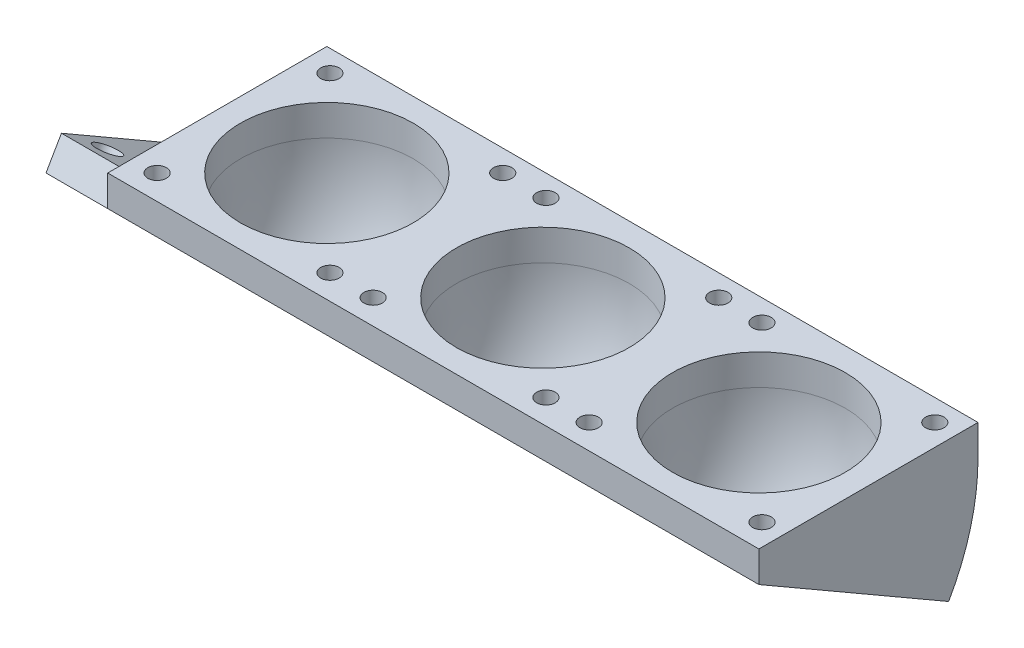
from build123d import *

# Parameters (mm, degrees)
SKETCH1_W           = 71
SKETCH1_H           = 71
SKETCH1_R           = 3
SKETCH1_R_2         = 28
BOSS_EXTRUDE1_DEPTH = 10
SKETCH2_W           = 71
SKETCH2_H           = 71
SKETCH2_R           = 28
REVOLVE1_ANGLE      = 30
LPATTERN1_COUNT     = 3
LPATTERN1_PITCH     = 70
SKETCH3_W           = 20
SKETCH3_H           = 71
BOSS_EXTRUDE2_DEPTH = 10
SKETCH4_R           = 4
CUT_EXTRUDE1_DEPTH  = 10


with BuildPart() as part:
    # Sketch1 → Boss-Extrude1 (new body)
    with BuildSketch(Plane(origin=(0, 0, 0), x_dir=(1, 0, 0), z_dir=(0, 1, 0))):
        with Locations((-15.992227979, 8.554404145)):
            Rectangle(SKETCH1_W, SKETCH1_H)
        with Locations((-43.492227979, 37.054404145)):
            Circle(SKETCH1_R, mode=Mode.SUBTRACT)
        with Locations((12.507772021, 37.054404145)):
            Circle(SKETCH1_R, mode=Mode.SUBTRACT)
        with Locations((12.507772021, -18.945595855)):
            Circle(SKETCH1_R, mode=Mode.SUBTRACT)
        with Locations((-43.492227979, -18.945595855)):
            Circle(SKETCH1_R, mode=Mode.SUBTRACT)
        with Locations((-15.992227979, 8.554404145)):
            Circle(SKETCH1_R_2, mode=Mode.SUBTRACT)
    boss_extrude1 = extrude(amount=BOSS_EXTRUDE1_DEPTH)

    # Sketch2 → Revolve1 (revolve)
    with BuildSketch(Plane.XZ):
        with Locations((-15.992227979, -8.554404145)):
            Rectangle(SKETCH2_W, SKETCH2_H)
        with Locations((-15.992227979, -8.554404145)):
            Circle(SKETCH2_R, mode=Mode.SUBTRACT)
    revolve1 = revolve(axis=Axis((19.507772021, 0, 26.945595855), (-1, 0, 0)), revolution_arc=REVOLVE1_ANGLE)

    # LPattern1: Boss-Extrude1, Revolve1 ×3
    with Locations(*[(i * LPATTERN1_PITCH, 0, 0) for i in range(1, LPATTERN1_COUNT)]):
        add(boss_extrude1)
        add(revolve1)

    # Sketch3 → Boss-Extrude2 (add)
    with BuildSketch(Plane(origin=(0, -11.667785265, 6.736398964), x_dir=(1, 0, 0), z_dir=(0, -0.866025404, 0.5))):
        with Locations((-61.492227979, -12.16442947)):
            Rectangle(SKETCH3_W, SKETCH3_H)
    extrude(amount=-BOSS_EXTRUDE2_DEPTH)

    # Sketch4 → Cut-Extrude1 (cut)
    with BuildSketch(Plane(origin=(0, -11.667785265, 6.736398964), x_dir=(1, 0, 0), z_dir=(0, -0.866025404, 0.5))):
        with Locations((-63.492227979, 15.33557053)):
            Circle(SKETCH4_R)
        with Locations((-63.492227979, -39.66442947)):
            Circle(SKETCH4_R)
    extrude(amount=-CUT_EXTRUDE1_DEPTH, mode=Mode.SUBTRACT)


solid = part.part
